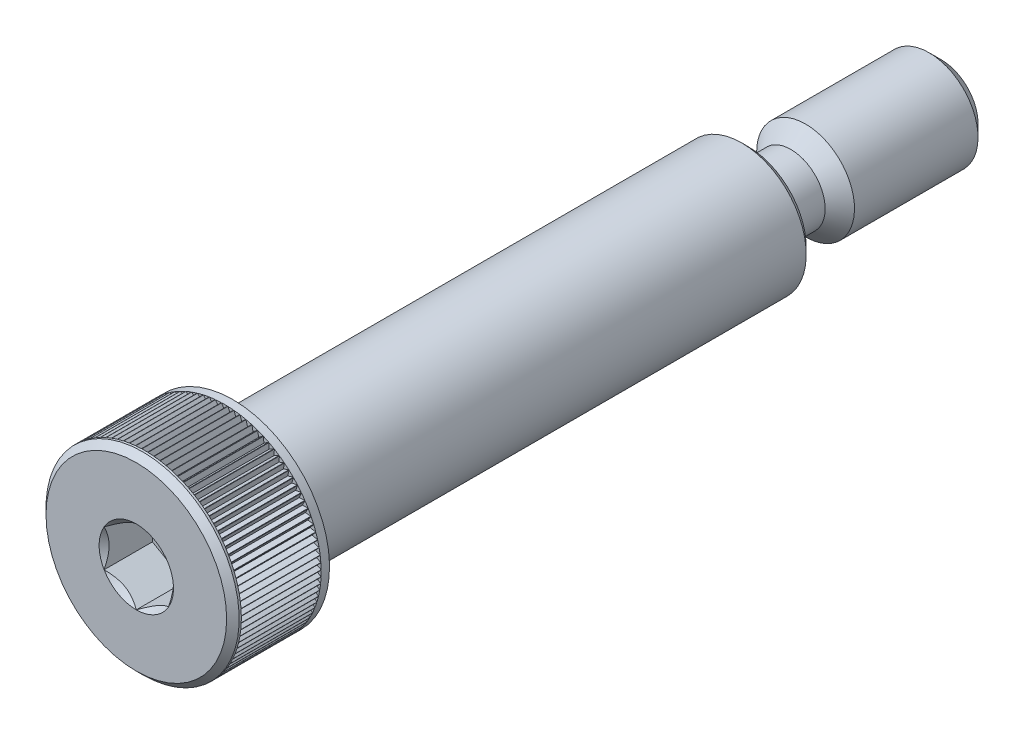
from build123d import *

# Parameters (mm, degrees)
CHAMFER1_SIZE      = 0.60325
CHAMFER2_SIZE      = 0.3095625
CUT_EXTRUDE5_DEPTH = 1.968103125
CIRPATTERN1_COUNT  = 99
CUT_EXTRUDE2_DEPTH = 2.38125


with BuildPart() as part:
    # Sketch1 → Revolve1 (revolve)
    with BuildSketch(Plane(origin=(0, 0, 0), x_dir=(0, 0, -1), z_dir=(1, 0, 0))):
        Polygon((0, 4.7625), (4.7625, 4.7625), (4.7625, 3.175), (30.1625, 3.175), (30.1625, 2.413), (39.6875, 2.413), (39.6875, 0), (0, 0), align=None)
    revolve(axis=Axis((0, 0, -39.6875), (0, 0, 1)))

    # Sketch5 → Cut-Revolve1 (revolve, cut)
    with BuildSketch(Plane(origin=(0, 0, 0), x_dir=(0, 0, -1), z_dir=(1, 0, 0))):
        with BuildLine():
            Line((30.1625, 3.175), (33.7566, 3.175))
            Line((33.7566, 3.175), (32.2707, 1.6891))
            Line((32.2707, 1.6891), (30.8864, 1.6891))
            ThreePointArc((30.8864, 1.6891), (30.374525401, 1.901125401), (30.1625, 2.413))
            Line((30.1625, 2.413), (30.1625, 3.175))
        make_face()
    revolve(axis=Axis((0, 0, -39.6875), (0, 0, 1)), mode=Mode.SUBTRACT)

    # Chamfer1
    chamfer1_edges = [part.edges().sort_by_distance(p)[0] for p in [
        (0, -2.413, -39.6875),
    ]]
    chamfer(chamfer1_edges, length=CHAMFER1_SIZE)

    # Chamfer2
    chamfer2_edges = [part.edges().sort_by_distance(p)[0] for p in [
        (0, -4.7625, 0),
        (0, -3.175, -30.1625),
    ]]
    chamfer(chamfer2_edges, length=CHAMFER2_SIZE)

    # Sketch11 → Cut-Extrude5 (cut, symmetric)
    with BuildSketch(Plane.XY.offset(-2.38125)):
        Polygon((0, 4.51485), (0.142980794, 4.7625), (-0.142980794, 4.7625), align=None)
    cut_extrude5 = extrude(amount=CUT_EXTRUDE5_DEPTH, both=True, mode=Mode.SUBTRACT)

    # CirPattern1: Cut-Extrude5 ×99 about axis
    cirpattern1_axis = Axis((0, 0, -39.6875), (0, 0, -1))
    for i in range(1, CIRPATTERN1_COUNT):
        add(cut_extrude5.rotate(cirpattern1_axis, i * 360 / CIRPATTERN1_COUNT), mode=Mode.SUBTRACT)

    # Sketch8 → Cut-Extrude2 (cut)
    with BuildSketch(Plane.XY):
        Polygon((1.5875, 0.916543552), (0, 1.833087105), (-1.5875, 0.916543552), (-1.5875, -0.916543552), (0, -1.833087105), (1.5875, -0.916543552), align=None)
    extrude(amount=-CUT_EXTRUDE2_DEPTH, mode=Mode.SUBTRACT)

    # Cut-Extrude4 cone 1 section (through the dimple's axis) → Cut-Extrude4 (revolve, cut)
    with BuildSketch(Plane(origin=(0, 0, 0), x_dir=(0, -1, 0), z_dir=(1, 0, 0))):
        Polygon((0, 0), (1.833087105, 0), (0, 1.833087105), align=None)
    revolve(axis=Axis((0, 0, 0), (0, 0, -1)), mode=Mode.SUBTRACT)


solid = part.part
